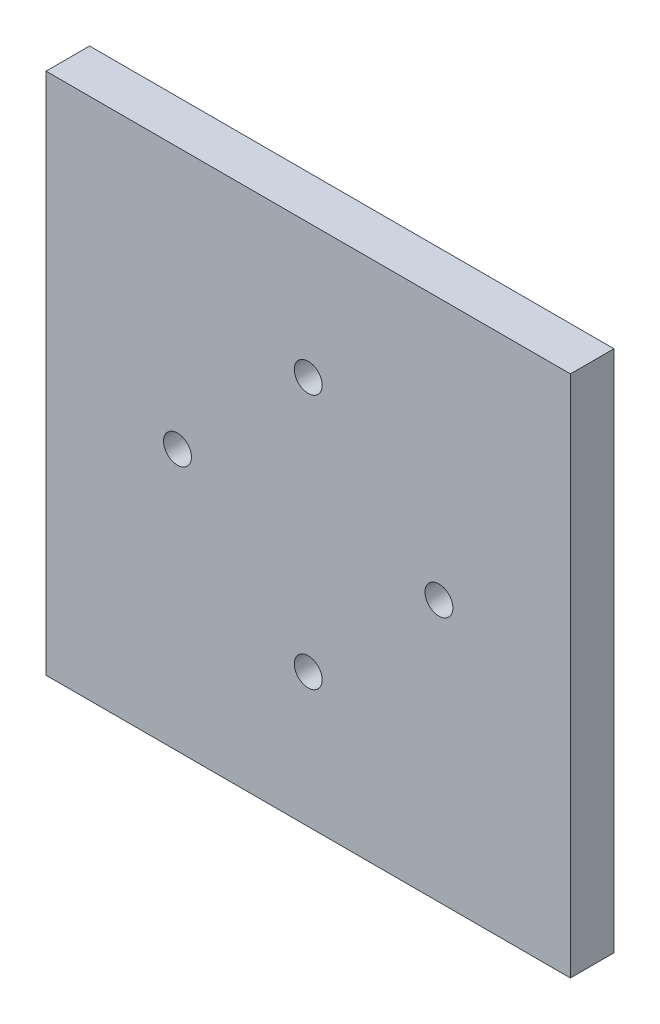
from build123d import *

# Parameters (mm, degrees)
SKETCH2_W           = 76.41689312
SKETCH2_H           = 76.245033474
SKETCH2_R           = 2.032
BOSS_EXTRUDE1_DEPTH = 6.35


with BuildPart() as part:
    # Sketch2 → Boss-Extrude1 (new body)
    with BuildSketch(Plane.XY):
        with Locations((-3.175, 3.175)):
            Rectangle(SKETCH2_W, SKETCH2_H)
        with Locations((-22.225, 3.175)):
            Circle(SKETCH2_R, mode=Mode.SUBTRACT)
        with Locations((15.875, 3.175)):
            Circle(SKETCH2_R, mode=Mode.SUBTRACT)
        with Locations((-3.175, 21.757669528)):
            Circle(SKETCH2_R, mode=Mode.SUBTRACT)
        with Locations((-3.175, -15.407669528)):
            Circle(SKETCH2_R, mode=Mode.SUBTRACT)
    extrude(amount=BOSS_EXTRUDE1_DEPTH)


solid = part.part
